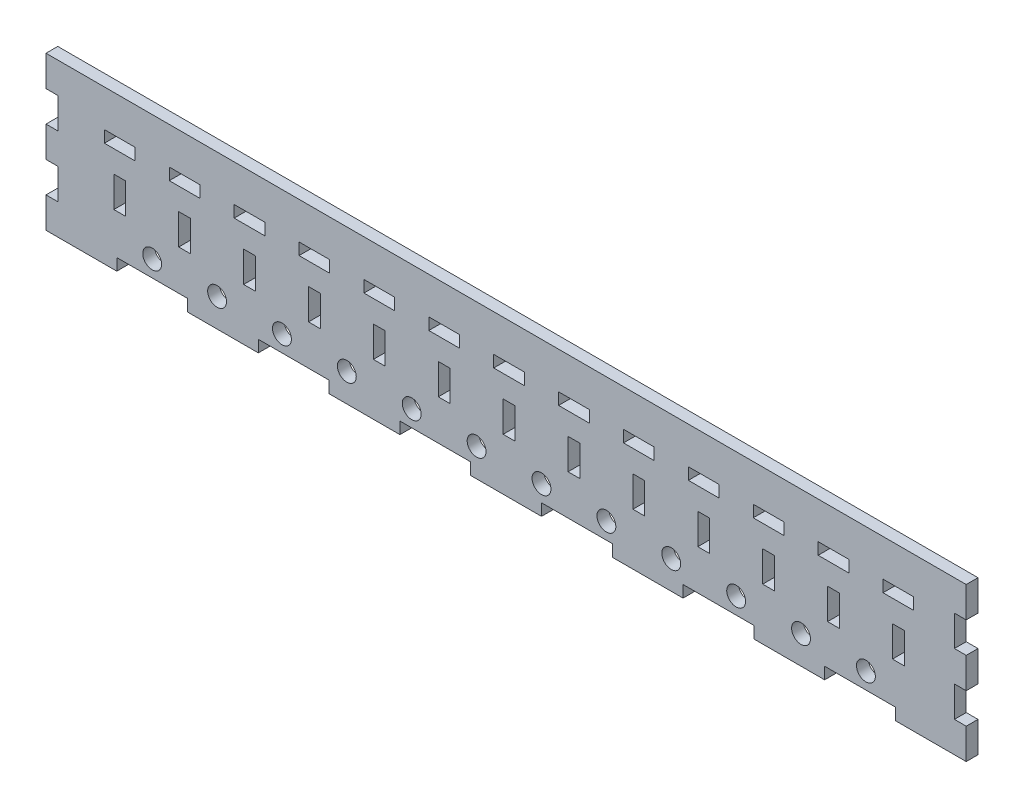
from build123d import *

# Parameters (mm, degrees)
ESQUISSE1_W                    = 390
ESQUISSE1_H                    = 65
BOSS_EXTRU_1_DEPTH             = 5
ESQUISSE2_W                    = 30
ESQUISSE2_H                    = 5
ENL_V_MAT_EXTRU_1_DEPTH        = 5
R_P_TITION_LIN_AIRE1_COUNT     = 6
R_P_TITION_LIN_AIRE1_PITCH     = 60
ESQUISSE3_W                    = 5
ESQUISSE3_H                    = 13
ENL_V_MAT_EXTRU_2_DEPTH        = 5
R_P_TITION_LIN_AIRE2_COUNT     = 2
R_P_TITION_LIN_AIRE2_PITCH     = 26
SYM_TRIE1_COPY_1_SKETCH_W      = 5
SYM_TRIE1_COPY_1_SKETCH_H      = 13
SYM_TRIE1_COPY_1_DEPTH         = 5
ESQUISSE5_R                    = 4
ENL_V_MAT_EXTRU_4_DEPTH        = 5
R_P_TITION_LIN_AIRE4_COUNT     = 10
R_P_TITION_LIN_AIRE4_PITCH     = 27.5
R_P_TITION_LIN_AIRE4_COL_COUNT = 3
R_P_TITION_LIN_AIRE4_COL_PITCH = 27.5
ESQUISSE4_W                    = 5
ESQUISSE4_H                    = 13
ESQUISSE4_W_2                  = 13
ESQUISSE4_H_2                  = 5
ENL_V_MAT_EXTRU_3_DEPTH        = 5
R_P_TITION_LIN_AIRE3_COUNT     = 3
R_P_TITION_LIN_AIRE3_PITCH     = 27.5
R_P_TITION_LIN_AIRE3_COL_COUNT = 11
R_P_TITION_LIN_AIRE3_COL_PITCH = 27.5


with BuildPart() as part:
    # Esquisse1 → Boss.-Extru.1 (new body)
    with BuildSketch(Plane.XY):
        with Locations((195, -32.5)):
            Rectangle(ESQUISSE1_W, ESQUISSE1_H)
    extrude(amount=BOSS_EXTRU_1_DEPTH)

    # Esquisse2 → Enlèv. mat.-Extru.1 (cut)
    with BuildSketch(Plane.XY.offset(5)):
        with Locations((45, -62.5)):
            Rectangle(ESQUISSE2_W, ESQUISSE2_H)
    enl_v_mat_extru_1 = extrude(amount=-ENL_V_MAT_EXTRU_1_DEPTH, mode=Mode.SUBTRACT)

    # Répétition linéaire1: Enlèv. mat.-Extru.1 ×6
    with Locations(*[(i * R_P_TITION_LIN_AIRE1_PITCH, 0, 0) for i in range(1, R_P_TITION_LIN_AIRE1_COUNT)]):
        add(enl_v_mat_extru_1, mode=Mode.SUBTRACT)

    # Esquisse3 → Enlèv. mat.-Extru.2 (cut)
    with BuildSketch(Plane.XY.offset(5)):
        with Locations((2.5, -45.5)):
            Rectangle(ESQUISSE3_W, ESQUISSE3_H)
    enl_v_mat_extru_2 = extrude(amount=-ENL_V_MAT_EXTRU_2_DEPTH, mode=Mode.SUBTRACT)

    # Répétition linéaire2: Enlèv. mat.-Extru.2 ×2
    with Locations(*[(0, i * R_P_TITION_LIN_AIRE2_PITCH, 0) for i in range(1, R_P_TITION_LIN_AIRE2_COUNT)]):
        add(enl_v_mat_extru_2, mode=Mode.SUBTRACT)

    # Symétrie1: Enlèv. mat.-Extru.2 across plane
    add(enl_v_mat_extru_2.mirror(Plane.ZY.offset(-195)), mode=Mode.SUBTRACT)

    # Symétrie1 copy 1 sketch → Symétrie1 copy 1 (cut)
    with BuildSketch(Plane(origin=(390, 26, 5), x_dir=(-1, 0, 0), z_dir=(0, 0, 1))):
        with Locations((2.5, 45.5)):
            Rectangle(SYM_TRIE1_COPY_1_SKETCH_W, SYM_TRIE1_COPY_1_SKETCH_H)
    extrude(amount=-SYM_TRIE1_COPY_1_DEPTH, mode=Mode.SUBTRACT)

    # Esquisse5 → Enlèv. mat.-Extru.4 (cut)
    with BuildSketch(Plane.XY.offset(5)):
        with Locations((100, -53)):
            Circle(ESQUISSE5_R)
    enl_v_mat_extru_4 = extrude(amount=-ENL_V_MAT_EXTRU_4_DEPTH, mode=Mode.SUBTRACT)

    # Répétition linéaire4: Enlèv. mat.-Extru.4 ×10
    with Locations(*[(i * R_P_TITION_LIN_AIRE4_PITCH, 0, 0) for i in range(1, R_P_TITION_LIN_AIRE4_COUNT)]):
        add(enl_v_mat_extru_4, mode=Mode.SUBTRACT)

    # Répétition linéaire4 col: Enlèv. mat.-Extru.4 ×3
    with Locations(*[(-i * R_P_TITION_LIN_AIRE4_COL_PITCH, 0, 0) for i in range(1, R_P_TITION_LIN_AIRE4_COL_COUNT)]):
        add(enl_v_mat_extru_4, mode=Mode.SUBTRACT)

    # Esquisse4 → Enlèv. mat.-Extru.3 (cut)
    with BuildSketch(Plane.XY.offset(5)):
        with Locations((86.25, -36.5)):
            Rectangle(ESQUISSE4_W, ESQUISSE4_H)
        with Locations((86.25, -18.15)):
            Rectangle(ESQUISSE4_W_2, ESQUISSE4_H_2)
    enl_v_mat_extru_3 = extrude(amount=-ENL_V_MAT_EXTRU_3_DEPTH, mode=Mode.SUBTRACT)

    # Répétition linéaire3: Enlèv. mat.-Extru.3 ×3
    with Locations(*[(-i * R_P_TITION_LIN_AIRE3_PITCH, 0, 0) for i in range(1, R_P_TITION_LIN_AIRE3_COUNT)]):
        add(enl_v_mat_extru_3, mode=Mode.SUBTRACT)

    # Répétition linéaire3 col: Enlèv. mat.-Extru.3 ×11
    with Locations(*[(i * R_P_TITION_LIN_AIRE3_COL_PITCH, 0, 0) for i in range(1, R_P_TITION_LIN_AIRE3_COL_COUNT)]):
        add(enl_v_mat_extru_3, mode=Mode.SUBTRACT)


solid = part.part
